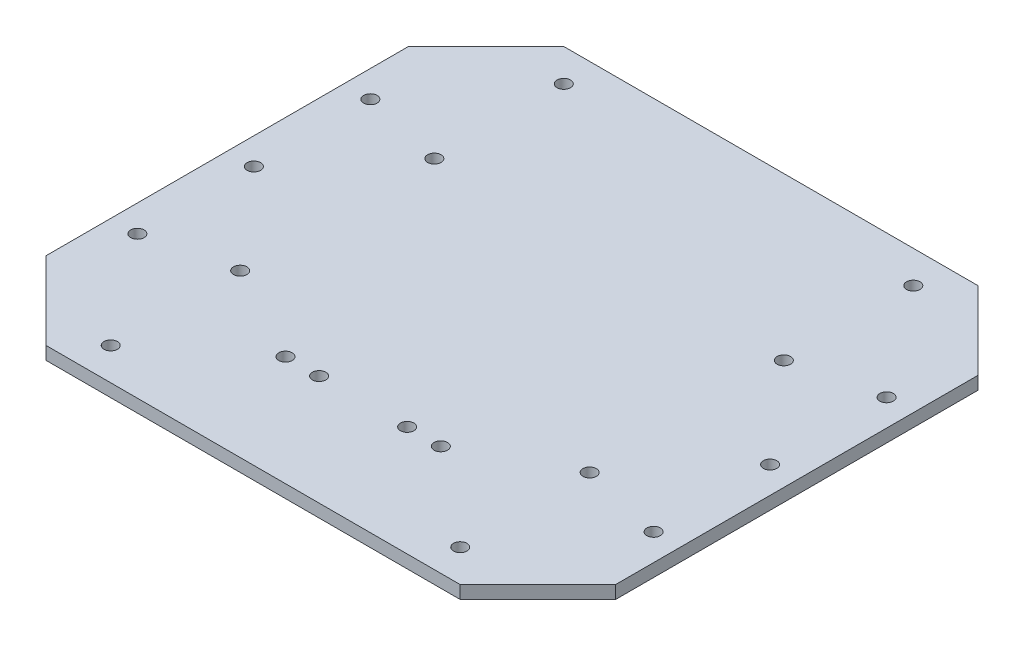
from build123d import *

# Parameters (mm, degrees)
SKETCH2_R           = 3.302
BOSS_EXTRUDE1_DEPTH = 6.35
SKETCH3_R           = 3.302
CUT_EXTRUDE1_DEPTH  = 7.35
SKETCH4_R           = 3.302
CUT_EXTRUDE2_DEPTH  = 7.35


with BuildPart() as part:
    # Sketch2 → Boss-Extrude1 (new body)
    with BuildSketch(Plane(origin=(0, 0, 0), x_dir=(1, 0, 0), z_dir=(0, 1, 0))):
        Polygon((-139.7, -88.9), (-139.7, 88.9), (-101.6, 127), (101.6, 127), (139.7, 88.9), (139.7, -88.9), (101.6, -127), (-101.6, -127), align=None)
        with Locations((-21.59, -73.025)):
            Circle(SKETCH2_R, mode=Mode.SUBTRACT)
        with Locations((-38.1, -73.025)):
            Circle(SKETCH2_R, mode=Mode.SUBTRACT)
        with Locations((38.1, -73.025)):
            Circle(SKETCH2_R, mode=Mode.SUBTRACT)
        with Locations((21.59, -73.025)):
            Circle(SKETCH2_R, mode=Mode.SUBTRACT)
    extrude(amount=BOSS_EXTRUDE1_DEPTH)

    # Sketch3 → Cut-Extrude1 (cut, through all)
    with BuildSketch(Plane(origin=(0, 6.35, 0), x_dir=(1, 0, 0), z_dir=(0, 1, 0))):
        with Locations((-126.619, 57.15)):
            Circle(SKETCH3_R)
        with Locations((-126.619, -57.15)):
            Circle(SKETCH3_R)
        with Locations((126.619, -57.15)):
            Circle(SKETCH3_R)
        with Locations((126.619, 0)):
            Circle(SKETCH3_R)
        with Locations((126.619, 57.15)):
            Circle(SKETCH3_R)
        with Locations((-126.619, 0)):
            Circle(SKETCH3_R)
    extrude(amount=-CUT_EXTRUDE1_DEPTH, mode=Mode.SUBTRACT)

    # Sketch4 → Cut-Extrude2 (cut, through all)
    with BuildSketch(Plane.XZ):
        with Locations((-85.725, 111.125)):
            Circle(SKETCH4_R)
        with Locations((-85.725, -111.125)):
            Circle(SKETCH4_R)
        with Locations((85.725, -111.125)):
            Circle(SKETCH4_R)
        with Locations((85.725, -47.625)):
            Circle(SKETCH4_R)
        with Locations((85.725, 47.625)):
            Circle(SKETCH4_R)
        with Locations((85.725, 111.125)):
            Circle(SKETCH4_R)
        with Locations((-85.725, 47.625)):
            Circle(SKETCH4_R)
        with Locations((-85.725, -47.625)):
            Circle(SKETCH4_R)
    extrude(amount=-CUT_EXTRUDE2_DEPTH, mode=Mode.SUBTRACT)


solid = part.part
